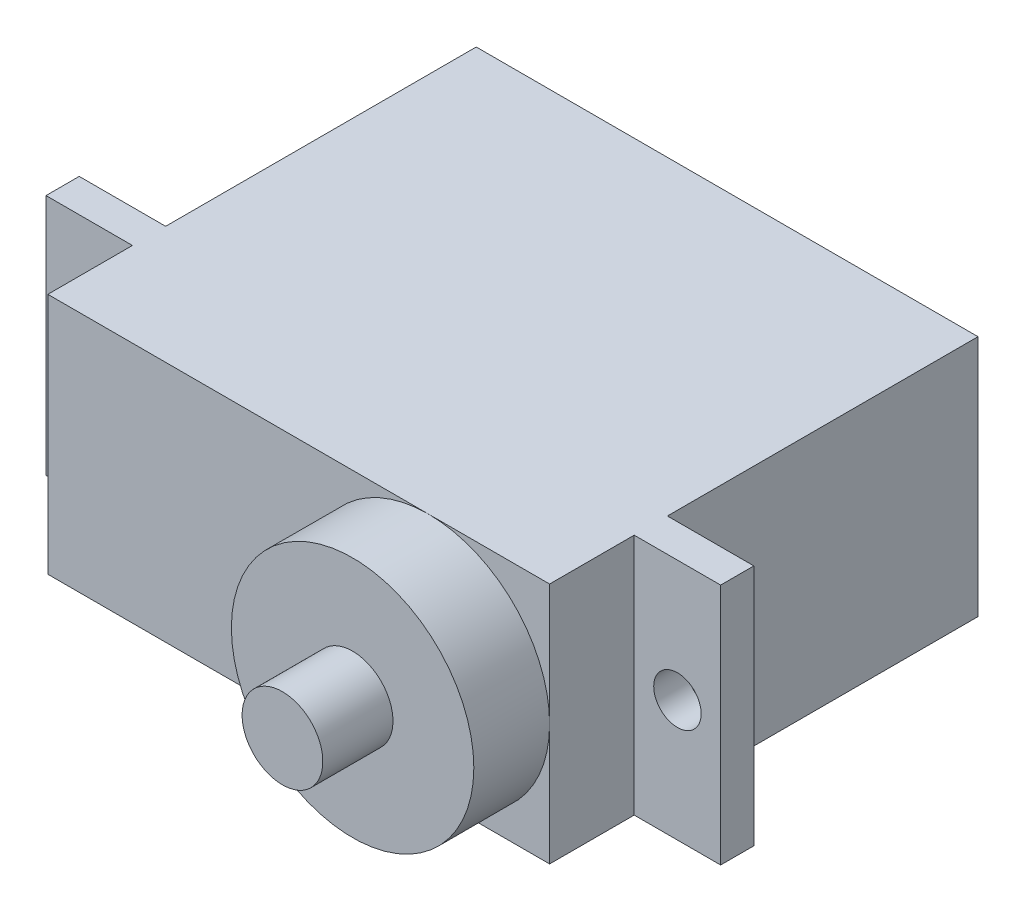
from build123d import *

# Parameters (mm, degrees)
SKETCH1_W           = 23.8
SKETCH1_H           = 11.5
BODY_DEPTH          = 20.32
SKETCH2_W           = 4.1
SKETCH2_H           = 11.5
SKETCH2_R           = 1.125
BOSS_EXTRUDE2_DEPTH = 1.5748
SKETCH3_R           = 1.915
BOSS_EXTRUDE3_DEPTH = 6.9215
SKETCH4_R           = 5.75
BOSS_EXTRUDE4_DEPTH = 3.5941


with BuildPart() as part:
    # Sketch1 → Body (new body)
    with BuildSketch(Plane.XY):
        Rectangle(SKETCH1_W, SKETCH1_H)
    extrude(amount=BODY_DEPTH)

    # Sketch2 → Boss-Extrude2 (add)
    with BuildSketch(Plane(origin=(0, 0, 14.732), x_dir=(-1, 0, 0), z_dir=(0, 0, -1))):
        with Locations((13.95, 0)):
            Rectangle(SKETCH2_W, SKETCH2_H)
        with Locations((13.95, 0)):
            Circle(SKETCH2_R, mode=Mode.SUBTRACT)
        with Locations((-13.95, 0)):
            Rectangle(SKETCH2_W, SKETCH2_H)
        with Locations((-13.95, 0)):
            Circle(SKETCH2_R, mode=Mode.SUBTRACT)
    extrude(amount=-BOSS_EXTRUDE2_DEPTH)

    # Sketch3 → Boss-Extrude3 (add)
    with BuildSketch(Plane.XY.offset(20.32)):
        with Locations((6.15, 0)):
            Circle(SKETCH3_R)
    extrude(amount=BOSS_EXTRUDE3_DEPTH)

    # Sketch4 → Boss-Extrude4 (add)
    with BuildSketch(Plane.XY.offset(20.32)):
        with Locations((6.15, 0)):
            Circle(SKETCH4_R)
    extrude(amount=BOSS_EXTRUDE4_DEPTH)


solid = part.part
